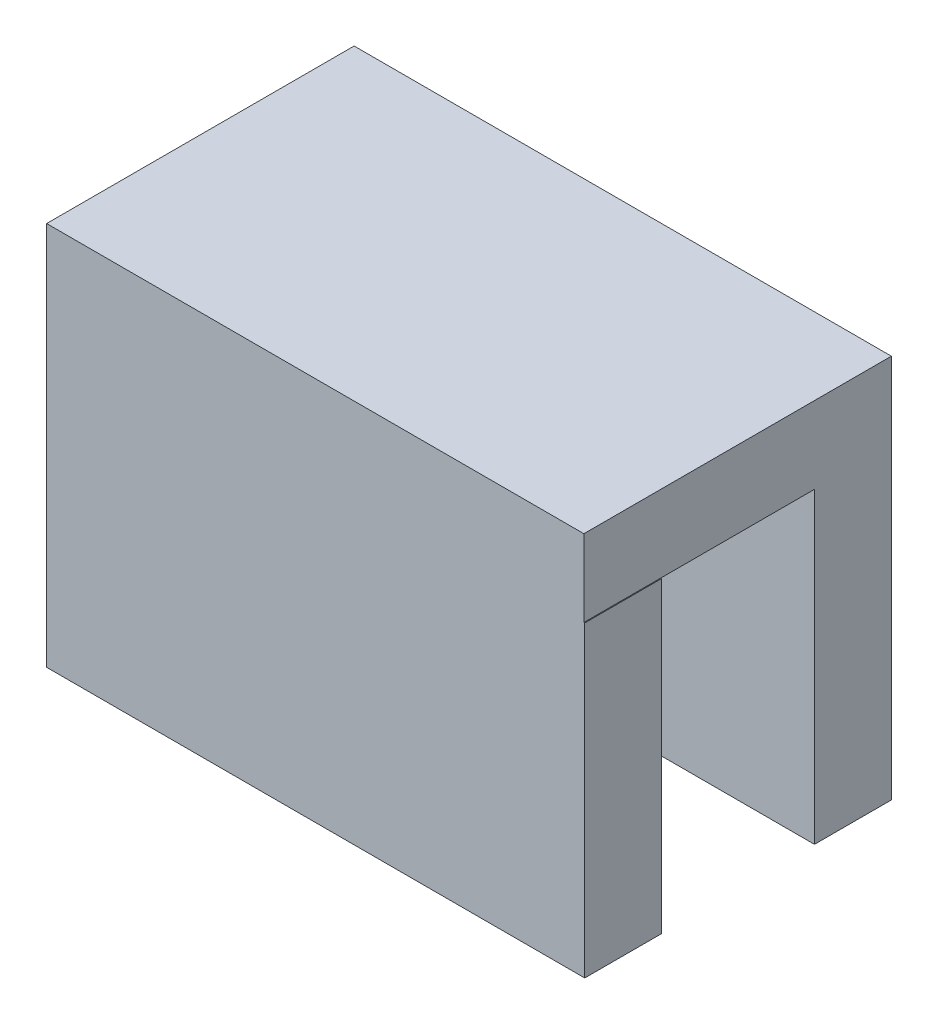
from build123d import *

# Parameters (mm, degrees)
SKETCH1_W           = 19.05
SKETCH1_H           = 12.7
BOSS_EXTRUDE1_DEPTH = 3.175
SKETCH3_W           = 19.014556256
SKETCH3_H           = 12.7
BOSS_EXTRUDE2_DEPTH = 3.175
SKETCH5_W           = 12.7
SKETCH5_H           = 15.875
BOSS_EXTRUDE4_DEPTH = 3.175
SKETCH6_R           = 2.54
CUT_EXTRUDE1_DEPTH  = 23.225
SKETCH4_W           = 19.014556256
SKETCH4_H           = 3.175
BOSS_EXTRUDE5_DEPTH = 12.7


with BuildPart() as part:
    # Sketch1 → Boss-Extrude1 (new body)
    with BuildSketch(Plane.XY):
        with Locations((9.525, 6.35)):
            Rectangle(SKETCH1_W, SKETCH1_H)
    extrude(amount=BOSS_EXTRUDE1_DEPTH)

    # Sketch3 → Boss-Extrude2 (add)
    with BuildSketch(Plane(origin=(0, 12.7, 0), x_dir=(1, 0, 0), z_dir=(0, 1, 0))):
        with Locations((9.507278128, 3.175)):
            Rectangle(SKETCH3_W, SKETCH3_H)
    extrude(amount=BOSS_EXTRUDE2_DEPTH)

    # Sketch5 → Boss-Extrude4 (add)
    with BuildSketch(Plane.ZY):
        with Locations((-3.175, 7.9375)):
            Rectangle(SKETCH5_W, SKETCH5_H)
    extrude(amount=BOSS_EXTRUDE4_DEPTH)

    # Sketch6 → Cut-Extrude1 (cut, through all)
    with BuildSketch(Plane.ZY.offset(3.175)):
        with Locations((-3.175, 5.08)):
            Circle(SKETCH6_R)
    extrude(amount=-CUT_EXTRUDE1_DEPTH, mode=Mode.SUBTRACT)

    # Sketch4 → Boss-Extrude5 (add)
    with BuildSketch(Plane.XZ.offset(-12.7)):
        with Locations((9.507278128, -7.9375)):
            Rectangle(SKETCH4_W, SKETCH4_H)
    extrude(amount=BOSS_EXTRUDE5_DEPTH)


solid = part.part
